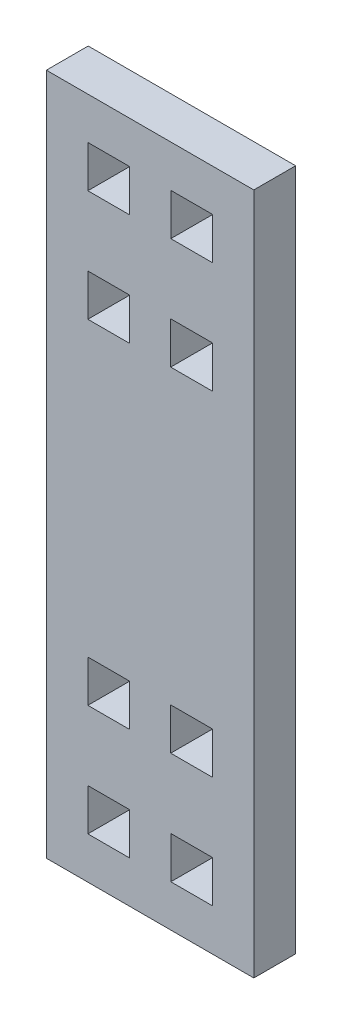
from build123d import *

# Parameters (mm, degrees)
SKETCH1_W           = 25.53
SKETCH1_H           = 84
BOSS_EXTRUDE1_DEPTH = 5.15
SKETCH2_W           = 5.106
SKETCH2_H           = 5.15
SKETCH2_W_2         = 5.15
CUT_EXTRUDE1_DEPTH  = 6.15


with BuildPart() as part:
    # Sketch1 → Boss-Extrude1 (new body)
    with BuildSketch(Plane.XY):
        with Locations((12.765, 42)):
            Rectangle(SKETCH1_W, SKETCH1_H)
    extrude(amount=BOSS_EXTRUDE1_DEPTH)

    # Sketch2 → Cut-Extrude1 (cut, through all)
    with BuildSketch(Plane.XY.offset(5.15)):
        with Locations((7.659, 76.275)):
            Rectangle(SKETCH2_W, SKETCH2_H)
        with Locations((17.871, 76.275)):
            Rectangle(SKETCH2_W, SKETCH2_H)
        with Locations((17.878171498, 21.425)):
            Rectangle(SKETCH2_W_2, SKETCH2_H)
        with Locations((7.681, 62.575)):
            Rectangle(SKETCH2_W_2, SKETCH2_H)
        with Locations((17.878171498, 62.575)):
            Rectangle(SKETCH2_W_2, SKETCH2_H)
        with Locations((7.681, 21.425)):
            Rectangle(SKETCH2_W_2, SKETCH2_H)
        with Locations((17.871, 7.725)):
            Rectangle(SKETCH2_W, SKETCH2_H)
        with Locations((7.659, 7.725)):
            Rectangle(SKETCH2_W, SKETCH2_H)
    extrude(amount=-CUT_EXTRUDE1_DEPTH, mode=Mode.SUBTRACT)


solid = part.part
